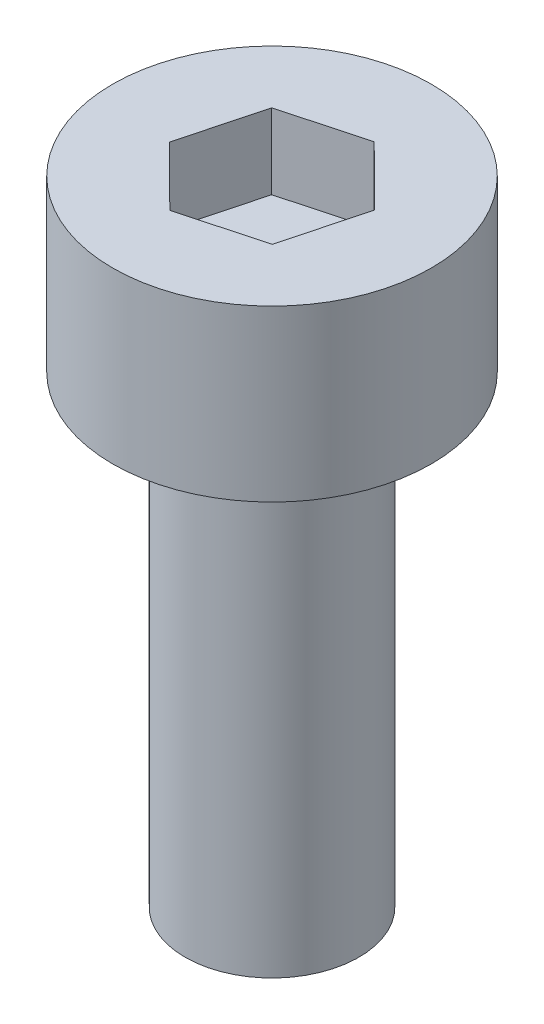
from build123d import *

# Parameters (mm, degrees)
SKETCH_1_R          = 1.5
EXTRUDE_1_DEPTH     = 8
SKETCH_2_R          = 2.75
EXTRUDE_2_DEPTH     = 2.93
CUT_EXTRUDE_1_DEPTH = 1.3


with BuildPart() as part:
    # 草图1 → 凸台-拉伸1 (new body)
    with BuildSketch(Plane(origin=(0, 0, 0), x_dir=(1, 0, 0), z_dir=(0, 1, 0))):
        Circle(SKETCH_1_R)
    extrude(amount=EXTRUDE_1_DEPTH)

    # 草图2 → 凸台-拉伸2 (add)
    with BuildSketch(Plane(origin=(0, 8, 0), x_dir=(1, 0, 0), z_dir=(0, 1, 0))):
        Circle(SKETCH_2_R)
    extrude(amount=EXTRUDE_2_DEPTH)

    # 草图3 → 切除-拉伸1 (cut)
    with BuildSketch(Plane(origin=(0, 10.93, 0), x_dir=(1, 0, 0), z_dir=(0, 1, 0))):
        Polygon((1.024005842, -1.017224346), (1.392945046, 0.378202899), (0.368939204, 1.395427245), (-1.024005842, 1.017224346), (-1.392945046, -0.378202899), (-0.368939204, -1.395427245), align=None)
    extrude(amount=-CUT_EXTRUDE_1_DEPTH, mode=Mode.SUBTRACT)


solid = part.part
